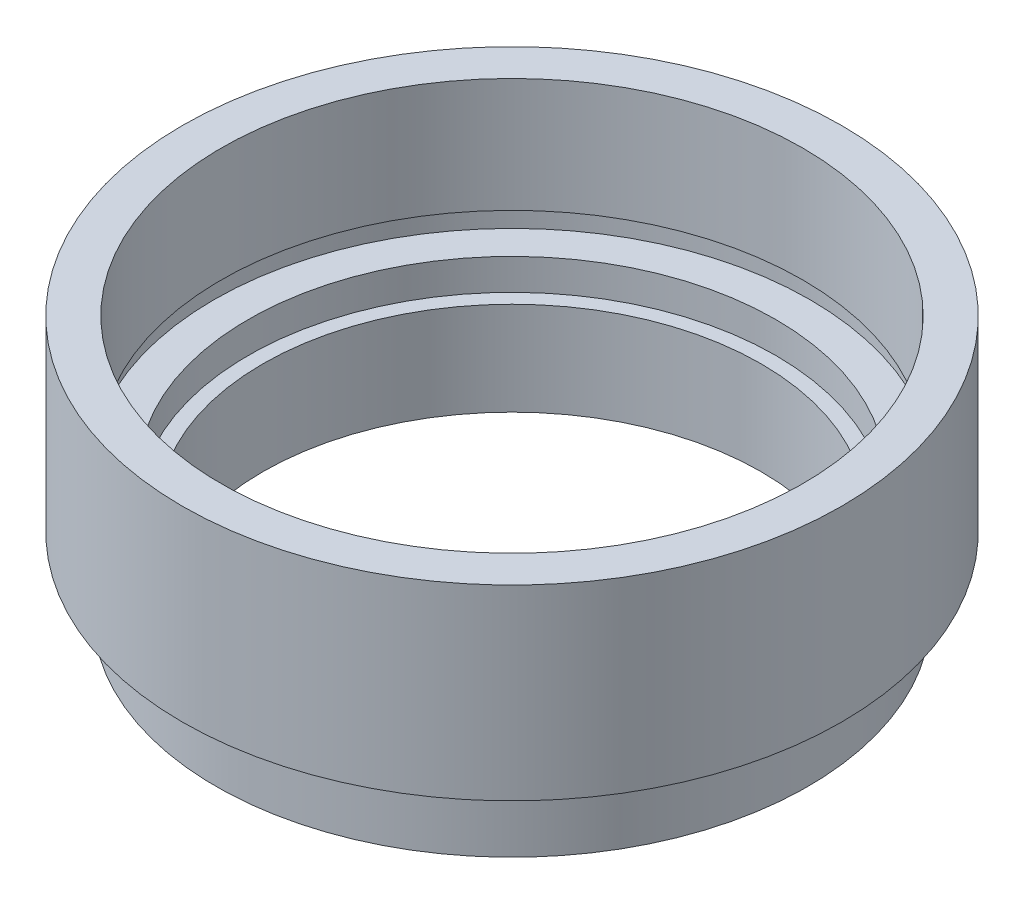
from build123d import *


with BuildPart() as part:
    # 草图1 → 旋转1 (revolve)
    with BuildSketch(Plane.XY, mode=Mode.PRIVATE) as revolve_1_sk:
        Polygon((12, 0), (14.25, 0), (14.25, 2.5), (13.75, 2.5), (13.75, 3.5), (15.875, 3.5), (15.875, 12.5), (14, 12.5), (14, 7), (14.35, 7), (14.35, 6), (12.7, 6), (12.7, 4.5), (12, 4.5), align=None)
    revolve(revolve_1_sk.sketch.rotate(Axis((0, 0, 0), (0, 1, 0)), 90), axis=Axis((0, 0, 0), (0, 1, 0)))  # turned: the seam where the file's is


solid = part.part
